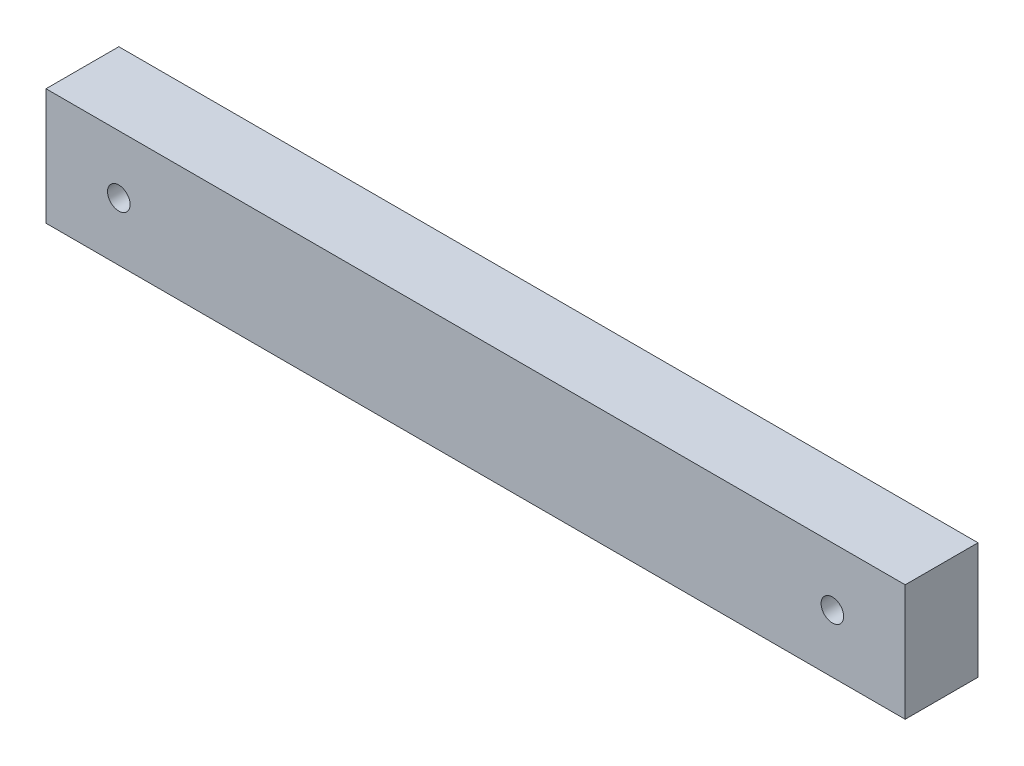
from build123d import *

# Parameters (mm, degrees)
SKETCH1_W           = 118
SKETCH1_H           = 16
SKETCH1_R           = 1.55
BOSS_EXTRUDE1_DEPTH = 10


with BuildPart() as part:
    # Sketch1 → Boss-Extrude1 (new body)
    with BuildSketch(Plane.XY):
        Rectangle(SKETCH1_W, SKETCH1_H)
        with Locations((-49, 0)):
            Circle(SKETCH1_R, mode=Mode.SUBTRACT)
        with Locations((49, 0)):
            Circle(SKETCH1_R, mode=Mode.SUBTRACT)
    extrude(amount=BOSS_EXTRUDE1_DEPTH)


solid = part.part
